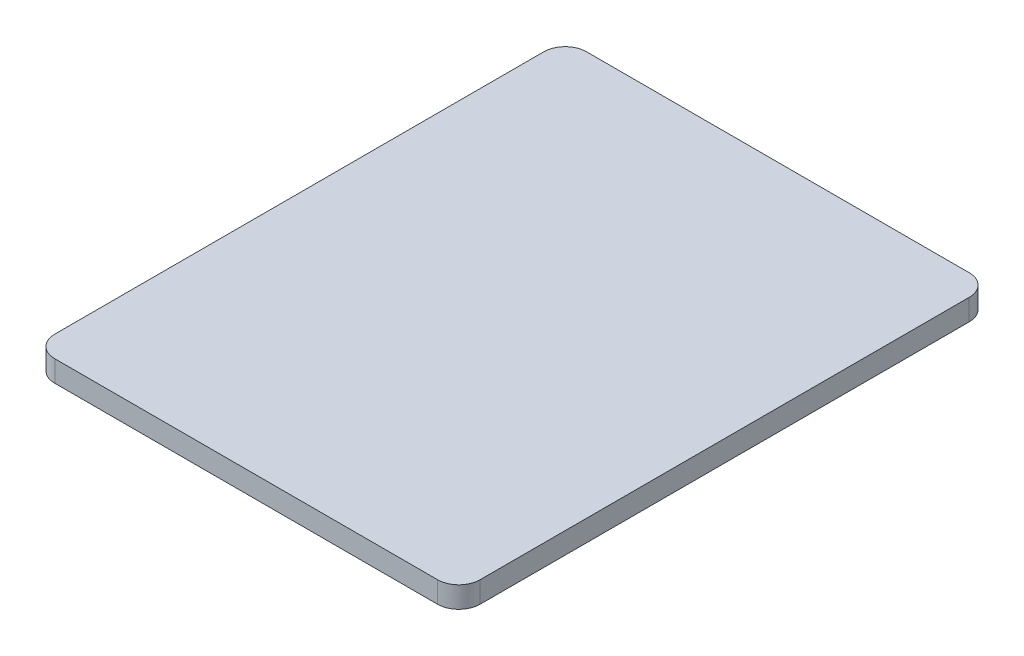
from build123d import *

# Parameters (mm, degrees)
SKETCH1_W           = 200
SKETCH1_H           = 250
BOSS_EXTRUDE1_DEPTH = 10
FILLET1_R           = 10
FILLET2_R           = 10


with BuildPart() as part:
    # Sketch1 → Boss-Extrude1 (new body)
    with BuildSketch(Plane(origin=(0, 0, 0), x_dir=(1, 0, 0), z_dir=(0, 1, 0))):
        Rectangle(SKETCH1_W, SKETCH1_H)
    extrude(amount=BOSS_EXTRUDE1_DEPTH)

    # Fillet1
    fillet1_edges = [part.edges().sort_by_distance(p)[0] for p in [
        (100, 5, 125),
        (100, 5, -125),
    ]]
    fillet(fillet1_edges, radius=FILLET1_R)

    # Fillet2
    fillet2_edges = [part.edges().sort_by_distance(p)[0] for p in [
        (-100, 5, 125),
        (-100, 5, -125),
    ]]
    fillet(fillet2_edges, radius=FILLET2_R)


solid = part.part
